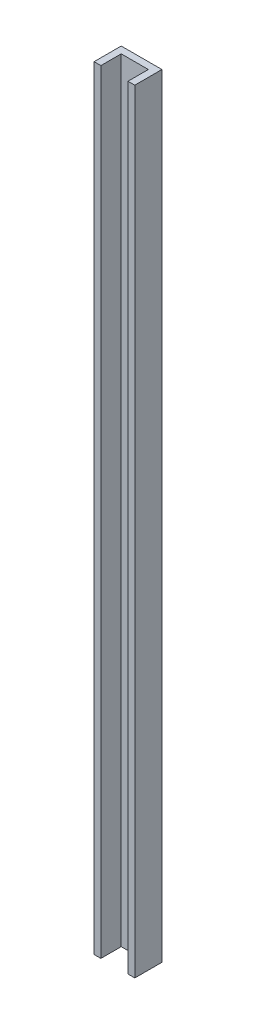
from build123d import *

# Parameters (mm, degrees)
BOSS_EXTRUDE1_DEPTH = 361.95


with BuildPart() as part:
    # Sketch1 → Boss-Extrude1 (new body)
    with BuildSketch(Plane(origin=(0, 0, 0), x_dir=(1, 0, 0), z_dir=(0, 1, 0))):
        Polygon((0, 0), (0, 12.7), (19.05, 12.7), (19.05, 0), (15.875, 0), (15.875, 9.525), (3.175, 9.525), (3.175, 0), align=None)
    extrude(amount=BOSS_EXTRUDE1_DEPTH)


solid = part.part
